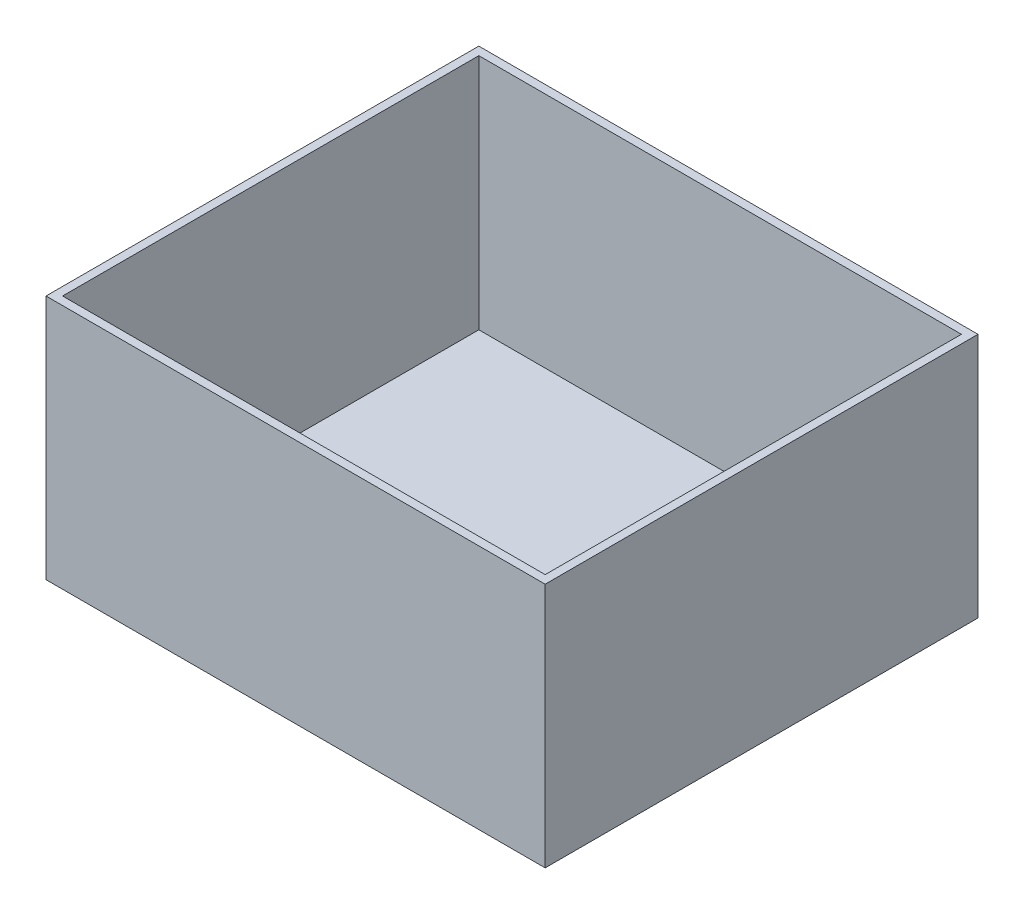
from build123d import *

# Parameters (mm, degrees)
SKETCH1_W           = 150.5
SKETCH1_H           = 130.5
SKETCH1_W_2         = 145.5
SKETCH1_H_2         = 125.5
BOSS_EXTRUDE1_DEPTH = 71.58
SKETCH3_W           = 150.5
SKETCH3_H           = 130.5
BOSS_EXTRUDE2_DEPTH = 2.5


with BuildPart() as part:
    # Sketch1 → Boss-Extrude1 (new body)
    with BuildSketch(Plane(origin=(0, 1.956589097, 0), x_dir=(1, 0, 0), z_dir=(0, 1, 0))):
        with Locations((81.927421255, -17.554481305)):
            Rectangle(SKETCH1_W, SKETCH1_H)
        with Locations((81.927421255, -17.554481305)):
            Rectangle(SKETCH1_W_2, SKETCH1_H_2, mode=Mode.SUBTRACT)
    extrude(amount=-BOSS_EXTRUDE1_DEPTH)

    # Sketch3 → Boss-Extrude2 (add)
    with BuildSketch(Plane(origin=(0, -69.623410903, 0), x_dir=(-1, 0, 0), z_dir=(0, -1, 0))):
        with Locations((-81.927421255, -17.554481305)):
            Rectangle(SKETCH3_W, SKETCH3_H)
    extrude(amount=BOSS_EXTRUDE2_DEPTH)


solid = part.part
